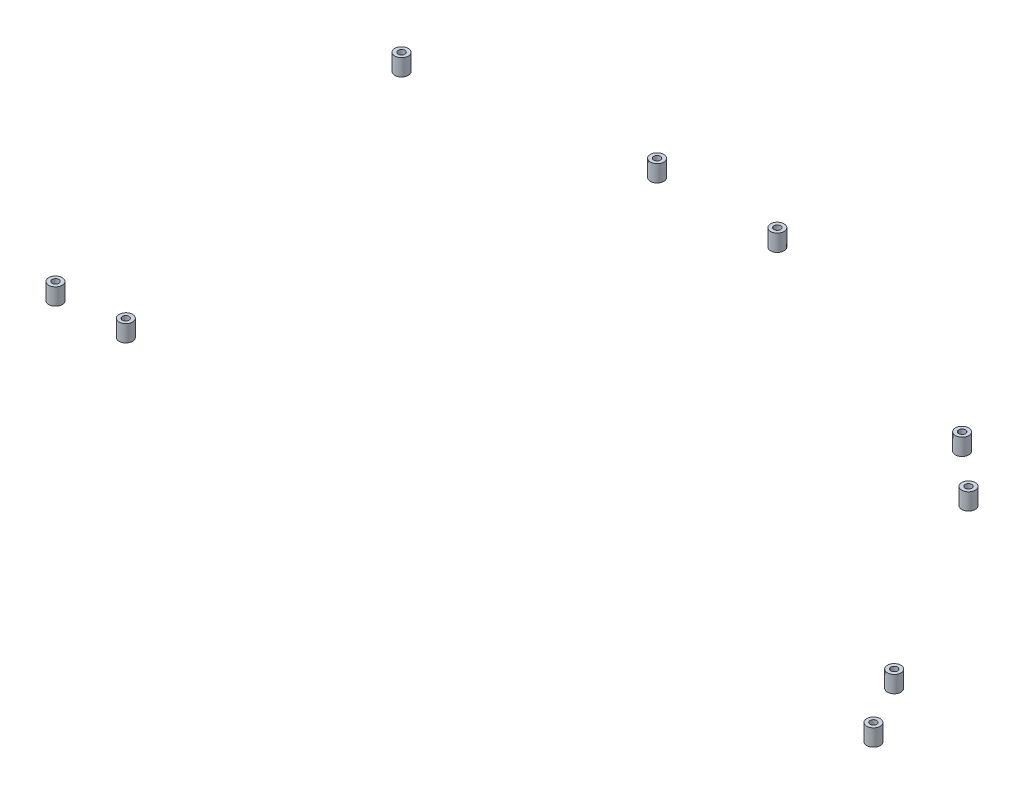
from build123d import *

# Parameters (mm, degrees)
SZKIC1_R                      = 4
SZKIC1_R_2                    = 2
DODANIE_WYCI_GNI_CIE1_DEPTH   = 10
DODANIE_WYCI_GNI_CIE1_2_DEPTH = 10
DODANIE_WYCI_GNI_CIE1_3_DEPTH = 10
SZKIC1_R_3                    = 3.999999999
DODANIE_WYCI_GNI_CIE1_4_DEPTH = 10
DODANIE_WYCI_GNI_CIE1_5_DEPTH = 10
DODANIE_WYCI_GNI_CIE1_6_DEPTH = 10
DODANIE_WYCI_GNI_CIE1_7_DEPTH = 10
DODANIE_WYCI_GNI_CIE1_8_DEPTH = 10
DODANIE_WYCI_GNI_CIE1_9_DEPTH = 10


with BuildPart() as part:
    # Szkic1 → Dodanie-wyciągnięcie1 (new body)
    with BuildSketch(Plane(origin=(3e-09, 444.999999998, -1e-09), x_dir=(1.0, -7.382198585065279e-12, 0), z_dir=(7.382198585065279e-12, 1.0, -2.0378698728507057e-12))):
        with Locations(Location((-572.687982619, -206.365683115, 0), (0, 0, 180))):
            Circle(SZKIC1_R)
        with Locations(Location((-572.687982619, -206.365683115, 0), (0, 0, 180))):
            Circle(SZKIC1_R_2, mode=Mode.SUBTRACT)
    extrude(amount=-DODANIE_WYCI_GNI_CIE1_DEPTH)


with BuildPart() as body_2:
    # Szkic1 → Dodanie-wyci_gni_cie1 2 (new body)
    with BuildSketch(Plane(origin=(3e-09, 444.999999998, -1e-09), x_dir=(1.0, -7.382198585065279e-12, 0), z_dir=(7.382198585065279e-12, 1.0, -2.0378698728507057e-12))):
        with Locations(Location((-441.663717113, -184.90636867, 0), (0, 0, 180))):
            Circle(SZKIC1_R)
        with Locations(Location((-441.663717113, -184.90636867, 0), (0, 0, 180))):
            Circle(SZKIC1_R_2, mode=Mode.SUBTRACT)
    extrude(amount=-DODANIE_WYCI_GNI_CIE1_2_DEPTH)


with BuildPart() as body_3:
    # Szkic1 → Dodanie-wyci_gni_cie1 3 (new body)
    with BuildSketch(Plane(origin=(3e-09, 444.999999998, -1e-09), x_dir=(1.0, -7.382198585065279e-12, 0), z_dir=(7.382198585065279e-12, 1.0, -2.0378698728507057e-12))):
        with Locations(Location((-369.907883252, -184.90636867, 0), (0, 0, 180))):
            Circle(SZKIC1_R)
        with Locations(Location((-369.907883252, -184.90636867, 0), (0, 0, 180))):
            Circle(SZKIC1_R_2, mode=Mode.SUBTRACT)
    extrude(amount=-DODANIE_WYCI_GNI_CIE1_3_DEPTH)


with BuildPart() as body_4:
    # Szkic1 → Dodanie-wyci_gni_cie1 4 (new body)
    with BuildSketch(Plane(origin=(3e-09, 444.999999998, -1e-09), x_dir=(1.0, -7.382198585065279e-12, 0), z_dir=(7.382198585065279e-12, 1.0, -2.0378698728507057e-12))):
        with Locations(Location((-209.29417775, -235.232823685, 0), (0, 0, 180))):
            Circle(SZKIC1_R_3)
        with Locations(Location((-209.29417775, -235.232823685, 0), (0, 0, 180))):
            Circle(SZKIC1_R_2, mode=Mode.SUBTRACT)
    extrude(amount=-DODANIE_WYCI_GNI_CIE1_4_DEPTH)


with BuildPart() as body_5:
    # Szkic1 → Dodanie-wyci_gni_cie1 5 (new body)
    with BuildSketch(Plane(origin=(3e-09, 444.999999998, -1e-09), x_dir=(1.0, -7.382198585065279e-12, 0), z_dir=(7.382198585065279e-12, 1.0, -2.0378698728507057e-12))):
        with Locations(Location((-179.166238962, -261.544556893, 0), (0, 0, 180))):
            Circle(SZKIC1_R_3)
        with Locations(Location((-179.166238962, -261.544556893, 0), (0, 0, 180))):
            Circle(SZKIC1_R_2, mode=Mode.SUBTRACT)
    extrude(amount=-DODANIE_WYCI_GNI_CIE1_5_DEPTH)


with BuildPart() as body_6:
    # Szkic1 → Dodanie-wyci_gni_cie1 6 (new body)
    with BuildSketch(Plane(origin=(3e-09, 444.999999998, -1e-09), x_dir=(1.0, -7.382198585065279e-12, 0), z_dir=(7.382198585065279e-12, 1.0, -2.0378698728507057e-12))):
        with Locations(Location((-106.94138654, -378.144106321, 0), (0, 0, 180))):
            Circle(SZKIC1_R)
        with Locations(Location((-106.94138654, -378.144106321, 0), (0, 0, 180))):
            Circle(SZKIC1_R_2, mode=Mode.SUBTRACT)
    extrude(amount=-DODANIE_WYCI_GNI_CIE1_6_DEPTH)


with BuildPart() as body_7:
    # Szkic1 → Dodanie-wyci_gni_cie1 7 (new body)
    with BuildSketch(Plane(origin=(3e-09, 444.999999998, -1e-09), x_dir=(1.0, -7.382198585065279e-12, 0), z_dir=(7.382198585065279e-12, 1.0, -2.0378698728507057e-12))):
        with Locations(Location((-85.513533734, -411.92053485, 0), (0, 0, 180))):
            Circle(SZKIC1_R)
        with Locations(Location((-85.513533734, -411.92053485, 0), (0, 0, 180))):
            Circle(SZKIC1_R_2, mode=Mode.SUBTRACT)
    extrude(amount=-DODANIE_WYCI_GNI_CIE1_7_DEPTH)


with BuildPart() as body_8:
    # Szkic1 → Dodanie-wyci_gni_cie1 8 (new body)
    with BuildSketch(Plane(origin=(3e-09, 444.999999998, -1e-09), x_dir=(1.0, -7.382198585065279e-12, 0), z_dir=(7.382198585065279e-12, 1.0, -2.0378698728507057e-12))):
        with BuildLine():
            add(Edge.make_bspline(
                [(-557.500474952, -432.076388533), (-549.500474952, -432.076388533), (-549.500474952, -424.076388533), (-557.500474952, -424.076388533), (-565.500474952, -424.076388533), (-565.500474952, -432.076388533), (-557.500474952, -432.076388533)],
                knots=[0, 0, 0, 0, 0.5, 0.5, 0.5, 1, 1, 1, 1], degree=3, weights=[1, 0.333333333, 0.333333333, 1, 0.333333333, 0.333333333, 1]))
        make_face()
        with Locations(Location((-557.500474952, -428.045174828, 0), (0, 0, 180))):
            Circle(SZKIC1_R_2, mode=Mode.SUBTRACT)
    extrude(amount=-DODANIE_WYCI_GNI_CIE1_8_DEPTH)


with BuildPart() as body_9:
    # Szkic1 → Dodanie-wyci_gni_cie1 9 (new body)
    with BuildSketch(Plane(origin=(3e-09, 444.999999998, -1e-09), x_dir=(1.0, -7.382198585065279e-12, 0), z_dir=(7.382198585065279e-12, 1.0, -2.0378698728507057e-12))):
        with BuildLine():
            add(Edge.make_bspline(
                [(-517.500474952, -430.079389266), (-509.500474952, -430.079389266), (-509.500474952, -422.079389266), (-517.500474952, -422.079389266), (-525.500474952, -422.079389266), (-525.500474952, -430.079389266), (-517.500474952, -430.079389266)],
                knots=[0, 0, 0, 0, 0.5, 0.5, 0.5, 1, 1, 1, 1], degree=3, weights=[1, 0.333333333, 0.333333333, 1, 0.333333333, 0.333333333, 1]))
        make_face()
        with Locations(Location((-517.500474952, -426.174740183, 0), (0, 0, 180))):
            Circle(SZKIC1_R_2, mode=Mode.SUBTRACT)
    extrude(amount=-DODANIE_WYCI_GNI_CIE1_9_DEPTH)


solid = Compound([part.part, body_2.part, body_3.part, body_4.part, body_5.part, body_6.part, body_7.part, body_8.part, body_9.part])
